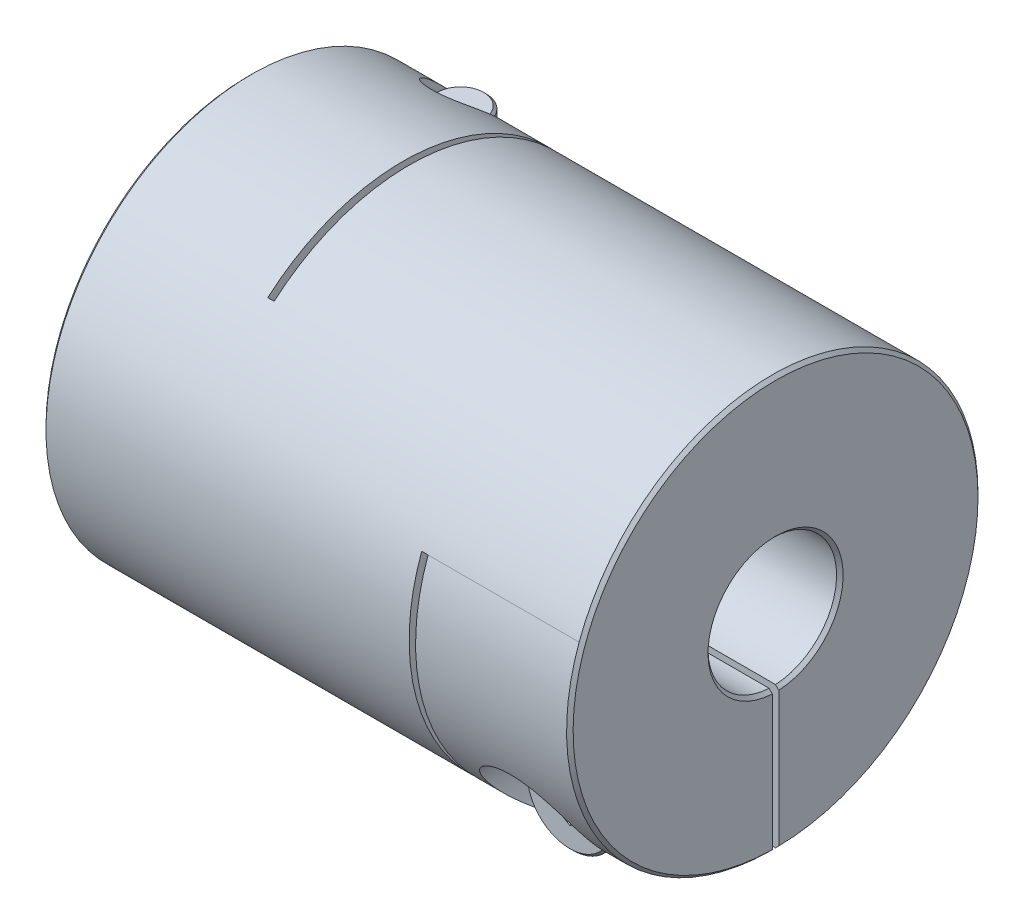
from build123d import *

# Parameters (mm, degrees)
SKETCH1_R                      = 16
BOSS_EXTRUDE1_DEPTH            = 20.5
SKETCH2_R                      = 5
CUT_EXTRUDE1_DEPTH             = 42
CHAMFER1_SIZE                  = 0.254
SKETCH4_W                      = 0.5
SKETCH4_H                      = 26.5
CUT_EXTRUDE2_DEPTH             = 33
SKETCH7_W                      = 0.5
SKETCH7_H                      = 21.5
CUT_EXTRUDE3_DEPTH             = 33
SKETCH8_W                      = 12
SKETCH8_H                      = 16
CUT_EXTRUDE5_DEPTH             = 0.25
SKETCH13_W                     = 12
SKETCH13_H                     = 16
CUT_EXTRUDE6_DEPTH             = 0.25
CBORE_FOR_M4_SHCS1_D           = 4.5
CBORE_FOR_M4_SHCS1_CBORE_D     = 8
CBORE_FOR_M4_SHCS1_CBORE_DEPTH = 10
CBORE_FOR_M4_SHCS2_D           = 4.5
CBORE_FOR_M4_SHCS2_CBORE_D     = 8
CBORE_FOR_M4_SHCS2_CBORE_DEPTH = 10
SKETCH16_R                     = 3.5
BOSS_EXTRUDE2_DEPTH            = 4
SKETCH17_R                     = 2
BOSS_EXTRUDE3_DEPTH            = 17.5
CHAMFER2_SIZE                  = 0.2
CUT_EXTRUDE7_DEPTH             = 1.5
CIRPATTERN1_COUNT              = 2
CIRPATTERN1_ANGLE              = 90


with BuildPart() as part:
    # Sketch1 → Boss-Extrude1 (new body, symmetric)
    with BuildSketch(Plane(origin=(0, 0, 0), x_dir=(0, 0, -1), z_dir=(1, 0, 0))):
        Circle(SKETCH1_R)
    extrude(amount=BOSS_EXTRUDE1_DEPTH, both=True)

    # Sketch2 → Cut-Extrude1 (cut, through all)
    with BuildSketch(Plane(origin=(20.5, 0, 0), x_dir=(0, 0, -1), z_dir=(1, 0, 0))):
        Circle(SKETCH2_R)
    extrude(amount=-CUT_EXTRUDE1_DEPTH, mode=Mode.SUBTRACT)

    # Chamfer1
    chamfer1_edges = [part.edges().sort_by_distance(p)[0] for p in [
        (-20.5, 0, 16),
        (20.5, 0, 16),
        (-20.5, 0, 5),
        (20.5, 0, 5),
    ]]
    chamfer(chamfer1_edges, length=CHAMFER1_SIZE)

    # Sketch4 → Cut-Extrude2 (cut, through all)
    with BuildSketch(Plane.XZ.offset(16)):
        with Locations((-8.25, -2.75)):
            Rectangle(SKETCH4_W, SKETCH4_H)
    extrude(amount=-CUT_EXTRUDE2_DEPTH, mode=Mode.SUBTRACT)

    # Sketch7 → Cut-Extrude3 (cut, through all)
    with BuildSketch(Plane(origin=(0, 0, -16), x_dir=(-1, 0, 0), z_dir=(0, 0, -1))):
        with Locations((-8.25, -5.25)):
            Rectangle(SKETCH7_W, SKETCH7_H)
    extrude(amount=-CUT_EXTRUDE3_DEPTH, mode=Mode.SUBTRACT)

    # Sketch8 → Cut-Extrude5 (cut, symmetric)
    with BuildSketch(Plane(origin=(0, 0, 0), x_dir=(1, 0, 0), z_dir=(0, 1, 0))):
        with Locations((-14.5, 8)):
            Rectangle(SKETCH8_W, SKETCH8_H)
    extrude(amount=CUT_EXTRUDE5_DEPTH, both=True, mode=Mode.SUBTRACT)

    # Sketch13 → Cut-Extrude6 (cut, symmetric)
    with BuildSketch(Plane.XY):
        with Locations((14.5, -8)):
            Rectangle(SKETCH13_W, SKETCH13_H)
    extrude(amount=CUT_EXTRUDE6_DEPTH, both=True, mode=Mode.SUBTRACT)

    # CBORE for M4 SHCS1 (through all)
    with Locations(Plane.XZ.offset(16)):
        with Locations((-14.5, -10.495896422)):
            CounterBoreHole(CBORE_FOR_M4_SHCS1_D / 2, CBORE_FOR_M4_SHCS1_CBORE_D / 2, CBORE_FOR_M4_SHCS1_CBORE_DEPTH)

    # CBORE for M4 SHCS2 (through all)
    with Locations(Plane.XY.offset(16)):
        with Locations((14.5, -10.495896422)):
            CounterBoreHole(CBORE_FOR_M4_SHCS2_D / 2, CBORE_FOR_M4_SHCS2_CBORE_D / 2, CBORE_FOR_M4_SHCS2_CBORE_DEPTH)


with BuildPart() as body_2:
    # Sketch16 → Boss-Extrude2 (new body)
    with BuildSketch(Plane.XY.offset(6)):
        with Locations((14.5, -10.495896422)):
            Circle(SKETCH16_R)
    extrude(amount=BOSS_EXTRUDE2_DEPTH)

    # Sketch17 → Boss-Extrude3 (add)
    with BuildSketch(Plane(origin=(0, 0, 6), x_dir=(-1, 0, 0), z_dir=(0, 0, -1))):
        with Locations(Location((-14.5, -10.495896422, 0), (0, 0, 180))):  # turned: the seam where the file's is
            Circle(SKETCH17_R)
    extrude(amount=BOSS_EXTRUDE3_DEPTH)

    # Chamfer2
    chamfer2_edges = [body_2.edges().sort_by_distance(p)[0] for p in [
        (11, -10.495896422, 6),
        (11, -10.495896422, 10),
        (12.5, -10.495896422, -11.5),
    ]]
    chamfer(chamfer2_edges, length=CHAMFER2_SIZE)

    # Sketch18 → Cut-Extrude7 (cut)
    with BuildSketch(Plane.XY.offset(10)):
        Polygon((14.5, -12.22794723), (16, -11.361921826), (16, -9.629871019), (14.5, -8.763845615), (13, -9.629871019), (13, -11.361921826), align=None)
    extrude(amount=-CUT_EXTRUDE7_DEPTH, mode=Mode.SUBTRACT)


with BuildPart() as body_3:
    # Mirror1: mirrored copy
    add(body_2.part.mirror(Plane(origin=(0, 0, 0), x_dir=(0, 0, 1), z_dir=(1, 0, 0))))


with BuildPart() as cirpattern1_1:
    # CirPattern1: pattern copy
    add(body_3.part.rotate(Axis((0, 0, 0), (1, 0, 0)), 1 * CIRPATTERN1_ANGLE / (CIRPATTERN1_COUNT - 1)))


solid = Compound([part.part, body_2.part, cirpattern1_1.part])
